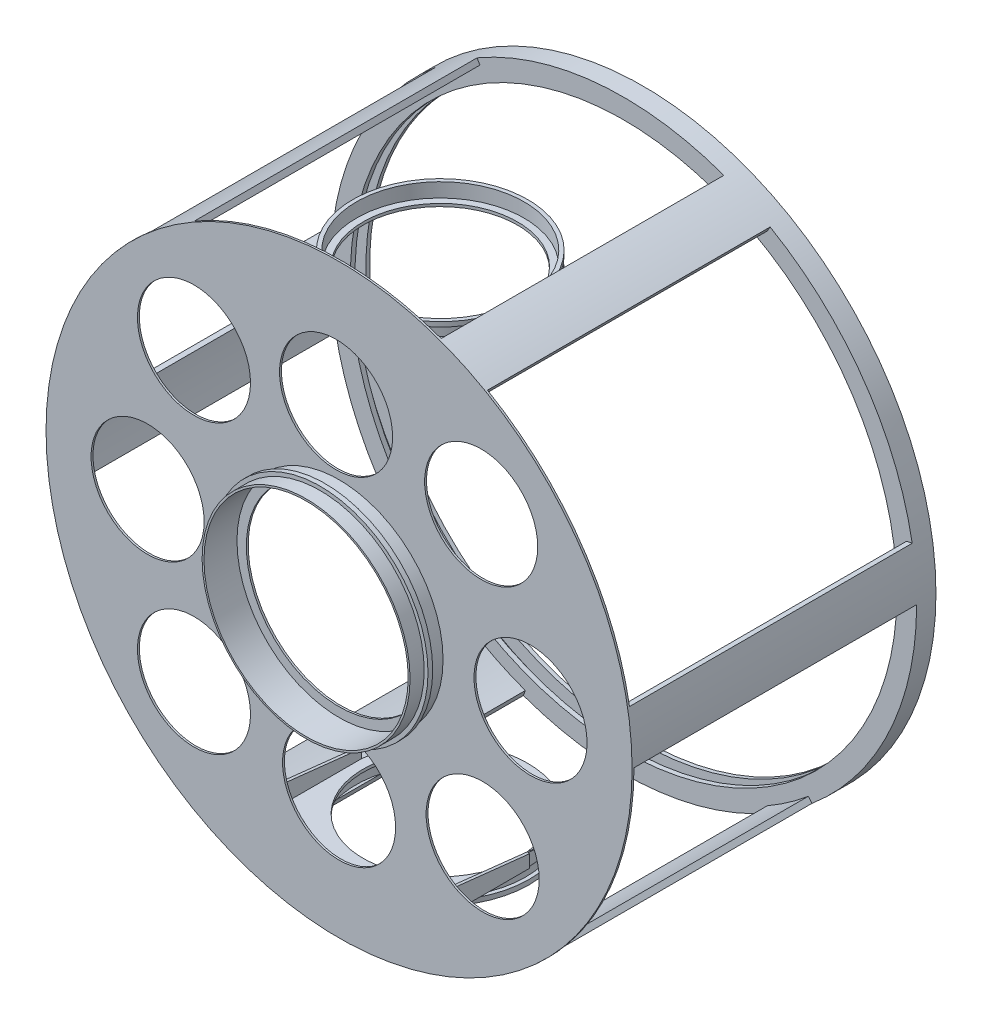
from build123d import *

# Parameters (mm, degrees)
SKETCH1_R                   = 311
SKETCH1_R_2                 = 290.1
EXTRUDE1_DEPTH              = 4
SKETCH3_R                   = 311
SKETCH3_R_2                 = 305
EXTRUDE2_DEPTH              = 11.5
SKETCH4_R                   = 311
SKETCH4_R_2                 = 290.1
EXTRUDE3_DEPTH              = 5
EXTRUDE4_DEPTH              = 300
SKETCH6_R                   = 311
EXTRUDE5_DEPTH              = 2
SKETCH7_R                   = 110.37
SKETCH7_R_2                 = 108.37
EXTRUDE6_DEPTH              = 15
SKETCH8_R                   = 114.4
SKETCH8_R_2                 = 108.37
EXTRUDE7_DEPTH              = 5
SKETCH9_R                   = 110.37
SKETCH9_R_2                 = 108.37
EXTRUDE8_DEPTH              = 15
EXTRUDE9_DEPTH              = 200
SKETCH11_R                  = 90.96
SKETCH11_R_2                = 88.96
EXTRUDE10_DEPTH             = 10
SKETCH13_R                  = 92.96
SKETCH13_R_2                = 88.96
EXTRUDE11_DEPTH             = 5
SKETCH14_R                  = 90.96
SKETCH14_R_2                = 88.96
EXTRUDE12_DEPTH             = 10
SKETCH15_R                  = 94.96
SKETCH15_R_2                = 88.96
EXTRUDE13_DEPTH             = 5
EXTRUDE14_REACH             = 221.04
EXTRUDE14_DIRECTION_2_REACH = 404.96
EXTRUDE15_REACH             = 221.04
EXTRUDE15_DIRECTION_2_REACH = 404.96
SKETCH18_R                  = 11.1125
SKETCH18_R_2                = 82
EXTRUDE16_DEPTH             = 25
SKETCH19_R                  = 11.1125
SKETCH19_R_2                = 82
EXTRUDE18_DEPTH             = 25
SKETCH20_R                  = 98.425
SKETCH20_R_2                = 60
EXTRUDE19_DEPTH             = 2


with BuildPart() as part:
    # Sketch1 → Extrude1 (new body)
    with BuildSketch(Plane.XY):
        Circle(SKETCH1_R)
        Circle(SKETCH1_R_2, mode=Mode.SUBTRACT)
    extrude(amount=EXTRUDE1_DEPTH)

    # Sketch3 → Extrude2 (add)
    with BuildSketch(Plane.XY.offset(4)):
        Circle(SKETCH3_R)
        Circle(SKETCH3_R_2, mode=Mode.SUBTRACT)
    extrude(amount=EXTRUDE2_DEPTH)

    # Sketch4 → Extrude3 (add)
    with BuildSketch(Plane.XY.offset(15.5)):
        Circle(SKETCH4_R)
        Circle(SKETCH4_R_2, mode=Mode.SUBTRACT)
    extrude(amount=EXTRUDE3_DEPTH)

    # Sketch5 → Extrude4 (add)
    with BuildSketch(Plane.XY.offset(20.5)):
        with BuildLine():
            Line((300.366364669, 52.962694188), (306.275211187, 54.004583254))
            ThreePointArc((306.275211187, 54.004583254), (309.816551107, 27.105435995), (311, 0))
            Line((311, 0), (305, 0))
            ThreePointArc((305, 0), (303.839382918, 26.582501538), (300.366364669, 52.962694188))
        make_face()
        with BuildLine():
            Line((152.5, 264.137748154), (155.5, 269.333900577))
            ThreePointArc((155.5, 269.333900577), (131.434279401, 281.861721768), (106.368264574, 292.244405064))
            Line((106.368264574, 292.244405064), (104.316143714, 286.60624934))
            ThreePointArc((104.316143714, 286.60624934), (128.898569831, 276.423875046), (152.5, 264.137748154))
        make_face()
        with BuildLine():
            Line((-152.5, 264.137748154), (-155.5, 269.333900577))
            ThreePointArc((-155.5, 269.333900577), (-178.382271705, 254.756285774), (-199.906946613, 238.23982181))
            Line((-199.906946613, 238.23982181), (-196.050220954, 233.643555151))
            ThreePointArc((-196.050220954, 233.643555151), (-174.940813087, 249.841373508), (-152.5, 264.137748154))
        make_face()
        with BuildLine():
            Line((-305, 0), (-311, 0))
            ThreePointArc((-311, 0), (-309.816551107, -27.105435995), (-306.275211187, -54.004583254))
            Line((-306.275211187, -54.004583254), (-300.366364669, -52.962694188))
            ThreePointArc((-300.366364669, -52.962694188), (-303.839382918, -26.582501538), (-305, 0))
        make_face()
        with BuildLine():
            Line((-152.5, -264.137748154), (-155.5, -269.333900577))
            ThreePointArc((-155.5, -269.333900577), (-131.434279401, -281.861721768), (-106.368264574, -292.244405064))
            Line((-106.368264574, -292.244405064), (-104.316143714, -286.60624934))
            ThreePointArc((-104.316143714, -286.60624934), (-128.898569831, -276.423875046), (-152.5, -264.137748154))
        make_face()
        with BuildLine():
            Line((152.5, -264.137748154), (155.5, -269.333900577))
            ThreePointArc((155.5, -269.333900577), (178.382271705, -254.756285774), (199.906946613, -238.23982181))
            Line((199.906946613, -238.23982181), (196.050220954, -233.643555151))
            ThreePointArc((196.050220954, -233.643555151), (174.940813087, -249.841373508), (152.5, -264.137748154))
        make_face()
    extrude(amount=EXTRUDE4_DEPTH)

    # Sketch6 → Extrude5 (add)
    with BuildSketch(Plane.XY.offset(320.5)):
        Circle(SKETCH6_R)
    extrude(amount=EXTRUDE5_DEPTH)

    # Sketch7 → Extrude6 (add)
    with BuildSketch(Plane.XY.offset(322.5)):
        Circle(SKETCH7_R)
        Circle(SKETCH7_R_2, mode=Mode.SUBTRACT)
    extrude(amount=EXTRUDE6_DEPTH)

    # Sketch8 → Extrude7 (add)
    with BuildSketch(Plane.XY.offset(337.5)):
        Circle(SKETCH8_R)
        Circle(SKETCH8_R_2, mode=Mode.SUBTRACT)
    extrude(amount=EXTRUDE7_DEPTH)

    # Sketch9 → Extrude8 (add)
    with BuildSketch(Plane.XY.offset(342.5)):
        Circle(SKETCH9_R)
        Circle(SKETCH9_R_2, mode=Mode.SUBTRACT)
    extrude(amount=EXTRUDE8_DEPTH)

    # Sketch10 → Extrude9 (add)
    with BuildSketch(Plane(origin=(0, 0, 320.5), x_dir=(-1, 0, 0), z_dir=(0, 0, -1))):
        Polygon((94.96, 250), (94.96, 228), (91.96, 228), (91.96, 250), (-91.96, 250), (-91.96, 228), (-94.96, 228), (-94.96, 250), (-94.96, 253), (0, 253), (94.96, 253), align=None)
        Polygon((94.96, -250), (94.96, -228), (91.96, -228), (91.96, -250), (-91.96, -250), (-91.96, -228), (-94.96, -228), (-94.96, -250), (-94.96, -253), (94.96, -253), align=None)
    extrude(amount=EXTRUDE9_DEPTH)

    # Sketch11 → Extrude10 (add)
    with BuildSketch(Plane(origin=(0, 253, 0), x_dir=(1, 0, 0), z_dir=(0, 1, 0))):
        with Locations((0.393539239, -215.46)):
            Circle(SKETCH11_R)
        with Locations((0.393539239, -215.46)):
            Circle(SKETCH11_R_2, mode=Mode.SUBTRACT)
    extrude(amount=EXTRUDE10_DEPTH)

    # Sketch13 → Extrude11 (add)
    with BuildSketch(Plane(origin=(0, 263, 0), x_dir=(1, 0, 0), z_dir=(0, 1, 0))):
        with Locations((0.393539239, -215.46)):
            Circle(SKETCH13_R)
        with Locations((0.393539239, -215.46)):
            Circle(SKETCH13_R_2, mode=Mode.SUBTRACT)
    extrude(amount=EXTRUDE11_DEPTH)

    # Sketch14 → Extrude12 (add)
    with BuildSketch(Plane.XZ.offset(253)):
        with Locations((0, 215.46)):
            Circle(SKETCH14_R)
        with Locations((0, 215.46)):
            Circle(SKETCH14_R_2, mode=Mode.SUBTRACT)
    extrude(amount=EXTRUDE12_DEPTH)

    # Sketch15 → Extrude13 (add)
    with BuildSketch(Plane.XZ.offset(263)):
        with Locations((0, 215.46)):
            Circle(SKETCH15_R)
        with Locations((0, 215.46)):
            Circle(SKETCH15_R_2, mode=Mode.SUBTRACT)
    extrude(amount=EXTRUDE13_DEPTH)

    # Extrude14: up to this face of the body (flat: up to its plane)
    extrude14_end = Plane(part.part.faces().sort_by_distance((94.96, 240.5, 220.5))[0])
    # Sketch16 → Extrude14 (cut, up to the picked face)
    with BuildSketch(Plane.ZY.offset(-91.96), mode=Mode.PRIVATE) as extrude14_sk1:
        Polygon((120.5, 228), (320.5, 228), (120.5, 250), align=None)
    extrude14_tool1 = split(extrude(extrude14_sk1.sketch, amount=-EXTRUDE14_REACH, mode=Mode.PRIVATE), bisect_by=extrude14_end, keep=Keep.BOTH, mode=Mode.PRIVATE)
    add(extrude14_tool1.solids().sort_by_distance((91.96, 235.333333, 187.166667))[0], mode=Mode.SUBTRACT)

    # Extrude14 direction 2: up to this face of the body (flat: up to its plane)
    extrude14_direction_2_end = Plane(part.part.faces().sort_by_distance((-94.96, 240.5, 220.5))[0])
    # Sketch16 → Extrude14 direction 2 (cut, up to the picked face)
    with BuildSketch(Plane.ZY.offset(-91.96), mode=Mode.PRIVATE) as extrude14_direction_2_sk1:
        Polygon((120.5, 228), (320.5, 228), (120.5, 250), align=None)
    extrude14_direction_2_tool1 = split(extrude(extrude14_direction_2_sk1.sketch, amount=EXTRUDE14_DIRECTION_2_REACH, mode=Mode.PRIVATE), bisect_by=extrude14_direction_2_end, keep=Keep.BOTH, mode=Mode.PRIVATE)
    add(extrude14_direction_2_tool1.solids().sort_by_distance((91.96, 235.333333, 187.166667))[0], mode=Mode.SUBTRACT)

    # Extrude15: up to this face of the body (flat: up to its plane)
    extrude15_end = Plane(part.part.faces().sort_by_distance((-94.96, -240.5, 220.5))[0])
    # Sketch17 → Extrude15 (cut, up to the picked face)
    with BuildSketch(Plane(origin=(-91.96, 0, 0), x_dir=(0, 0, -1), z_dir=(1, 0, 0)), mode=Mode.PRIVATE) as extrude15_sk1:
        Polygon((-320.5, -228), (-120.5, -228), (-120.5, -250), align=None)
    extrude15_tool1 = split(extrude(extrude15_sk1.sketch, amount=-EXTRUDE15_REACH, mode=Mode.PRIVATE), bisect_by=extrude15_end, keep=Keep.BOTH, mode=Mode.PRIVATE)
    add(extrude15_tool1.solids().sort_by_distance((-91.96, -235.333333, 187.166667))[0], mode=Mode.SUBTRACT)

    # Extrude15 direction 2: up to this face of the body (flat: up to its plane)
    extrude15_direction_2_end = Plane(part.part.faces().sort_by_distance((94.96, -240.5, 220.5))[0])
    # Sketch17 → Extrude15 direction 2 (cut, up to the picked face)
    with BuildSketch(Plane(origin=(-91.96, 0, 0), x_dir=(0, 0, -1), z_dir=(1, 0, 0)), mode=Mode.PRIVATE) as extrude15_direction_2_sk1:
        Polygon((-320.5, -228), (-120.5, -228), (-120.5, -250), align=None)
    extrude15_direction_2_tool1 = split(extrude(extrude15_direction_2_sk1.sketch, amount=EXTRUDE15_DIRECTION_2_REACH, mode=Mode.PRIVATE), bisect_by=extrude15_direction_2_end, keep=Keep.BOTH, mode=Mode.PRIVATE)
    add(extrude15_direction_2_tool1.solids().sort_by_distance((-91.96, -235.333333, 187.166667))[0], mode=Mode.SUBTRACT)

    # Sketch18 → Extrude16 (cut)
    with BuildSketch(Plane(origin=(0, 253, 0), x_dir=(1, 0, 0), z_dir=(0, 1, 0))):
        with Locations((69.85, -304.8)):
            Circle(SKETCH18_R)
        with Locations((-69.85, -304.8)):
            Circle(SKETCH18_R)
        with Locations((0.393539239, -215.46)):
            Circle(SKETCH18_R_2)
        with BuildLine():
            Line((93.173539239, -215.46), (94.96, -215.46))
            Line((94.96, -215.46), (94.96, -120.5))
            Line((94.96, -120.5), (-94.96, -120.5))
            Line((-94.96, -120.5), (-94.96, -215.46))
            Line((-94.96, -215.46), (-92.386460761, -215.46))
            ThreePointArc((-92.386460761, -215.46), (0.393539239, -122.68), (93.173539239, -215.46))
        make_face()
    extrude(amount=-EXTRUDE16_DEPTH, mode=Mode.SUBTRACT)

    # Sketch19 → Extrude18 (cut)
    with BuildSketch(Plane.XZ.offset(253)):
        with Locations((69.85, 304.8)):
            Circle(SKETCH19_R)
        with Locations((-69.85, 304.8)):
            Circle(SKETCH19_R)
        with Locations((0.393539239, 215.46)):
            Circle(SKETCH19_R_2)
        with BuildLine():
            Line((93.173539239, 215.46), (94.96, 215.46))
            Line((94.96, 215.46), (94.96, 120.5))
            Line((94.96, 120.5), (-94.96, 120.5))
            Line((-94.96, 120.5), (-94.96, 215.46))
            Line((-94.96, 215.46), (-92.386460761, 215.46))
            ThreePointArc((-92.386460761, 215.46), (0.393539239, 122.68), (93.173539239, 215.46))
        make_face()
    extrude(amount=-EXTRUDE18_DEPTH, mode=Mode.SUBTRACT)

    # Sketch20 → Extrude19 (cut)
    with BuildSketch(Plane.XY.offset(322.5)):
        Circle(SKETCH20_R)
        with Locations((203.2, 0)):
            Circle(SKETCH20_R_2)
        with Locations((150.8125, 153.9875)):
            Circle(SKETCH20_R_2)
        with Locations((-3.175, 177.8)):
            Circle(SKETCH20_R_2)
        with Locations((-153.9875, 152.4)):
            Circle(SKETCH20_R_2)
        with Locations((-203.2, 0)):
            Circle(SKETCH20_R_2)
        with Locations((-153.9875, -152.4)):
            Circle(SKETCH20_R_2)
        with Locations((0, -179.3875)):
            Circle(SKETCH20_R_2)
        with Locations((152.4, -150.8125)):
            Circle(SKETCH20_R_2)
    extrude(amount=-EXTRUDE19_DEPTH, mode=Mode.SUBTRACT)


solid = part.part
